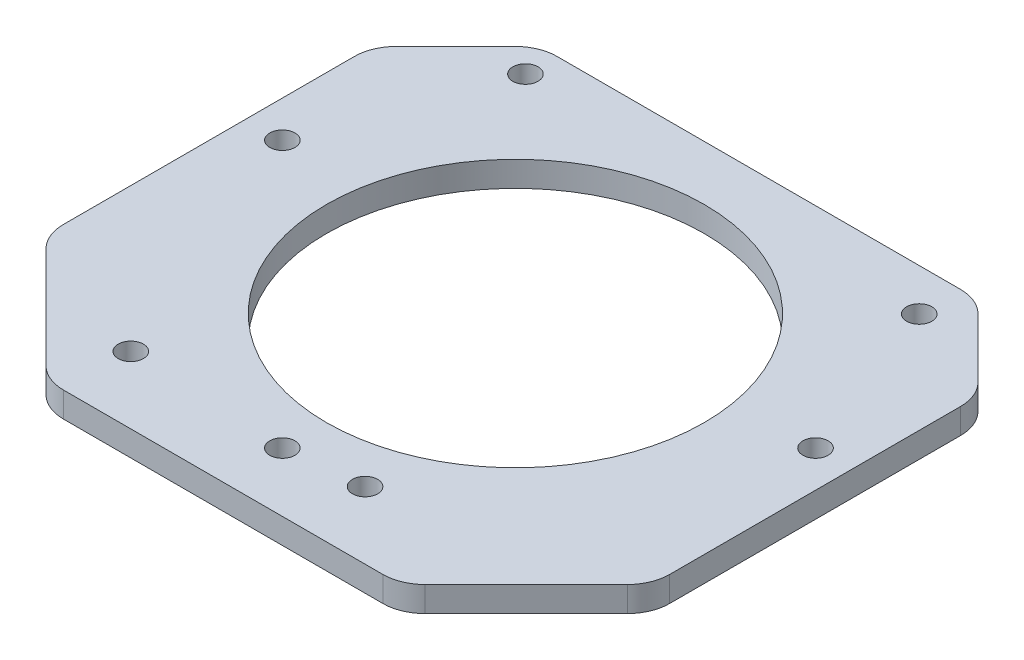
from build123d import *

# Parameters (mm, degrees)
SKETCH1_W           = 72.2
SKETCH1_H           = 63.8
SKETCH1_R           = 1.5
BOSS_EXTRUDE1_DEPTH = 1.5
CHAMFER1_SIZE       = 15
CHAMFER2_SIZE       = 10
SKETCH2_R           = 22.5
CUT_EXTRUDE1_DEPTH  = 4
FILLET1_R           = 5


with BuildPart() as part:
    # Sketch1 → Boss-Extrude1 (new body, symmetric)
    with BuildSketch(Plane(origin=(0, 0, 0), x_dir=(1, 0, 0), z_dir=(0, 1, 0))):
        with Locations((-8.9, -26.9)):
            Rectangle(SKETCH1_W, SKETCH1_H)
        with Locations((15.2, 0)):
            Circle(SKETCH1_R, mode=Mode.SUBTRACT)
        with Locations((0, -50.8)):
            Circle(SKETCH1_R, mode=Mode.SUBTRACT)
        with Locations((-27.9, -50.8)):
            Circle(SKETCH1_R, mode=Mode.SUBTRACT)
        with Locations((-33, 1.3)):
            Circle(SKETCH1_R, mode=Mode.SUBTRACT)
        with Locations((22.85, -20)):
            Circle(SKETCH1_R, mode=Mode.SUBTRACT)
        with Locations((-40.65, -20)):
            Circle(SKETCH1_R, mode=Mode.SUBTRACT)
        with Locations((-8.9, -51.75)):
            Circle(SKETCH1_R, mode=Mode.SUBTRACT)
    extrude(amount=BOSS_EXTRUDE1_DEPTH, both=True)

    # Chamfer1
    chamfer1_edges = [part.edges().sort_by_distance(p)[0] for p in [
        (27.2, 0, 58.8),
        (-45, 0, 58.8),
    ]]
    chamfer(chamfer1_edges, length=CHAMFER1_SIZE)

    # Chamfer2
    chamfer2_edges = [part.edges().sort_by_distance(p)[0] for p in [
        (-45, 0, -5),
        (27.2, 0, -5),
    ]]
    chamfer(chamfer2_edges, length=CHAMFER2_SIZE)

    # Sketch2 → Cut-Extrude1 (cut, through all)
    with BuildSketch(Plane.XZ.offset(1.5)):
        with Locations((-8.9, 24)):
            Circle(SKETCH2_R)
    extrude(amount=-CUT_EXTRUDE1_DEPTH, mode=Mode.SUBTRACT)

    # Fillet1
    fillet1_edges = [part.edges().sort_by_distance(p)[0] for p in [
        (27.2, 0, 43.8),
        (-30, 0, 58.8),
        (12.2, 0, 58.8),
        (-45, 0, 43.8),
        (-35, 0, -5),
        (17.2, 0, -5),
        (27.2, 0, 5),
        (-45, 0, 5),
    ]]
    fillet(fillet1_edges, radius=FILLET1_R)


solid = part.part
